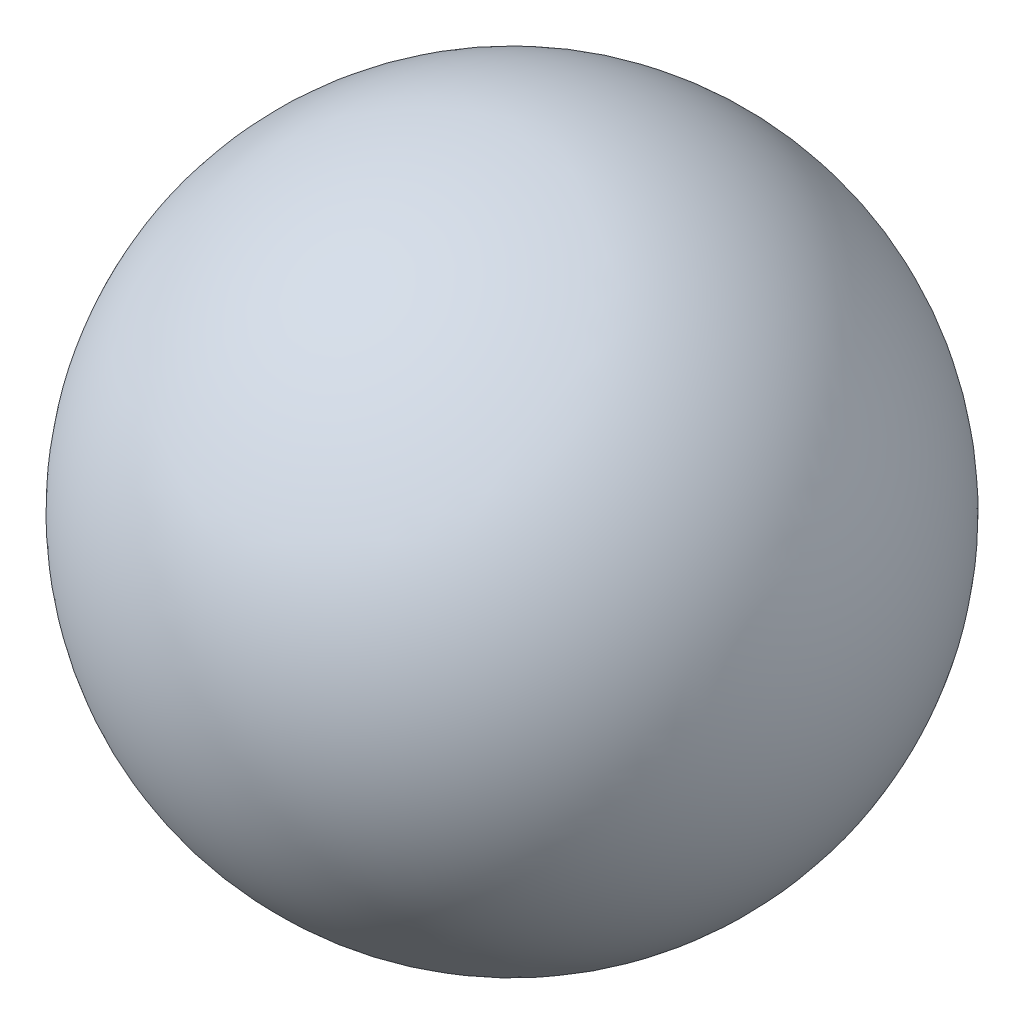
from build123d import *


with BuildPart() as part:
    # Sketch1 → Revolve1 (revolve)
    with BuildSketch(Plane(origin=(0, 0, 0), x_dir=(1, 0, 0), z_dir=(0, 1, 0))):
        with BuildLine():
            Line((-8, 0), (8, 0))
            ThreePointArc((8, 0), (0, -8), (-8, 0))
        make_face()
    revolve(axis=Axis((-8, 0, 0), (1, 0, 0)))


solid = part.part
